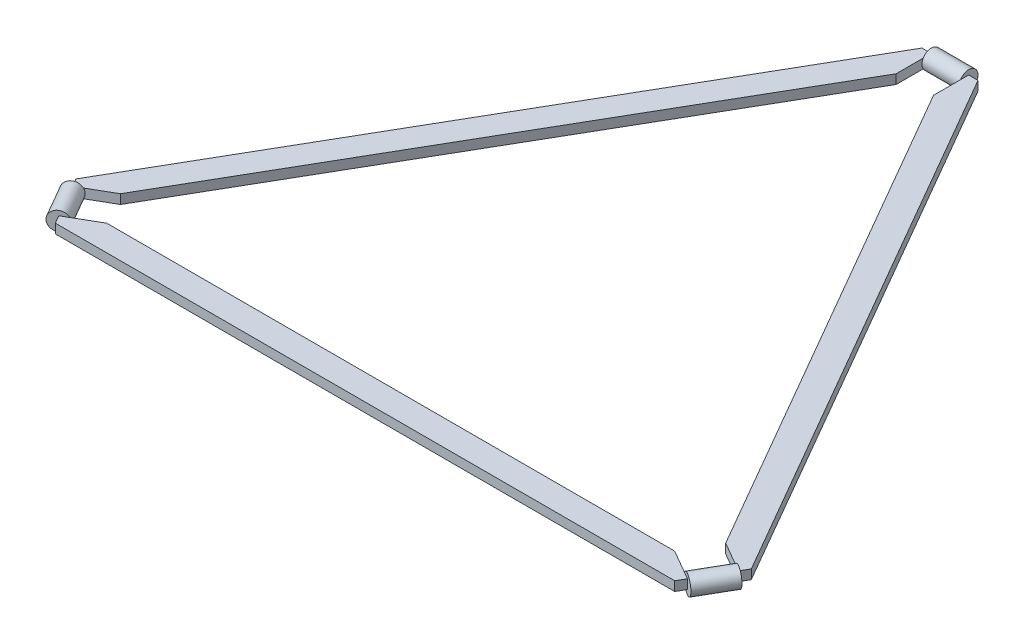
from build123d import *

# Parameters (mm, degrees)
SALIENTE_EXTRUIR2_DEPTH   = 5
SALIENTE_EXTRUIR2_2_DEPTH = 5
SALIENTE_EXTRUIR2_3_DEPTH = 5
SALIENTE_EXTRUIR3_START   = -20
CROQUIS5_R                = 10
SALIENTE_EXTRUIR3_DEPTH   = 40
CROQUIS6_R                = 10
SALIENTE_EXTRUIR4_DEPTH   = 40
CROQUIS7_R                = 10
SALIENTE_EXTRUIR5_DEPTH   = 40


with BuildPart() as part:
    # Croquis4 → Saliente-Extruir2 (new body, symmetric)
    with BuildSketch(Plane(origin=(0, 0, 0), x_dir=(1, 0, 0), z_dir=(0, 1, 0))):
        Polygon((-303.846502665, -198.519870873), (-336.410161514, -217.320508076), (-331.410161514, -225.980762114), (331.410161514, -225.980762114), (336.410161514, -217.320508076), (303.846502665, -198.519870873), align=None)
    extrude(amount=SALIENTE_EXTRUIR2_DEPTH, both=True)



with BuildPart() as body_2:
    # Croquis4 → Saliente-Extruir2 2 (new body, symmetric)
    with BuildSketch(Plane(origin=(0, 0, 0), x_dir=(1, 0, 0), z_dir=(0, 1, 0))):
        Polygon((-20, 400), (-30, 400), (-361.410161514, -174.019237886), (-356.410161514, -182.679491924), (-323.846502665, -163.878854722), (-20, 362.398725595), align=None)
    extrude(amount=SALIENTE_EXTRUIR2_2_DEPTH, both=True)



with BuildPart() as body_3:
    # Croquis4 → Saliente-Extruir2 3 (new body, symmetric)
    with BuildSketch(Plane(origin=(0, 0, 0), x_dir=(1, 0, 0), z_dir=(0, 1, 0))):
        Polygon((30, 400), (20, 400), (20, 362.398725595), (323.846502665, -163.878854722), (356.410161514, -182.679491924), (361.410161514, -174.019237886), align=None)
    extrude(amount=SALIENTE_EXTRUIR2_3_DEPTH, both=True)


with BuildPart() as body_2_1:
    add(body_2.part)

    add(body_3.part)  # Saliente-Extruir3 merges body 3
    # Croquis5 → Saliente-Extruir3 (add)
    with BuildSketch(Plane(origin=(0, 0, 0), x_dir=(0, 0, -1), z_dir=(1, 0, 0)).offset(SALIENTE_EXTRUIR3_START)):
        with Locations((400, 0)):
            Circle(CROQUIS5_R)
    extrude(amount=SALIENTE_EXTRUIR3_DEPTH)


with BuildPart() as part_1:
    add(part.part)

    add(body_2_1.part)  # Saliente-Extruir4 merges body 2
    # Croquis6 → Saliente-Extruir4 (add)
    with BuildSketch(Plane(origin=(-10, 0, -17.320508076), x_dir=(0.866025404, 0, -0.5), z_dir=(0.5, 0, 0.866025404))):
        with Locations((-400, 0)):
            Circle(CROQUIS6_R)
    extrude(amount=SALIENTE_EXTRUIR4_DEPTH)

    # Croquis7 → Saliente-Extruir5 (add)
    with BuildSketch(Plane(origin=(10, 0, -17.320508076), x_dir=(0.866025404, 0, 0.5), z_dir=(-0.5, 0, 0.866025404))):
        with Locations((400, 0)):
            Circle(CROQUIS7_R)
    extrude(amount=SALIENTE_EXTRUIR5_DEPTH)


solid = part_1.part
